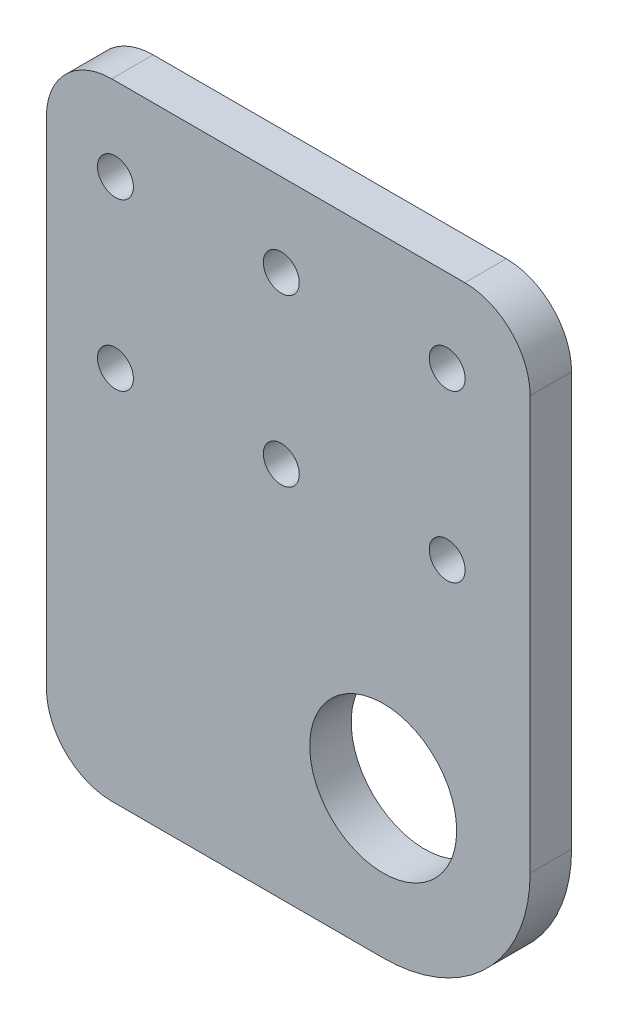
from build123d import *

# Parameters (mm, degrees)
SKETCH1_W            = 74.07
SKETCH1_H            = 50.8
BOSS_EXTRUDE1_DEPTH  = 6.35
FILLET1_R            = 10
M5_CLEARANCE_HOLE1_D = 5.5
BOSS_EXTRUDE2_DEPTH  = 6.35
SKETCH5_R            = 11.25
CUT_EXTRUDE1_DEPTH   = 7.35
FILLET2_R            = 10
FILLET3_R            = 22.5


with BuildPart() as part:
    # Sketch1 → Boss-Extrude1 (new body)
    with BuildSketch(Plane.XY):
        Rectangle(SKETCH1_W, SKETCH1_H)
    extrude(amount=BOSS_EXTRUDE1_DEPTH)

    # Fillet1
    fillet1_edges = [part.edges().sort_by_distance(p)[0] for p in [
        (-37.035, 25.4, 3.175),
        (37.035, 25.4, 3.175),
        (37.035, -25.4, 3.175),
        (-37.035, -25.4, 3.175),
    ]]
    fillet(fillet1_edges, radius=FILLET1_R)

    # M5 Clearance Hole1 (through all)
    with Locations(Plane.XY.offset(6.35)):
        with Locations((-26.465, 12.7), (-26.465, -12.7), (-1.065, -12.7), (-1.065, 12.7), (24.335, 12.7), (24.335, -12.7)):
            Hole(M5_CLEARANCE_HOLE1_D / 2)

    # Sketch4 → Boss-Extrude2 (add)
    with BuildSketch(Plane.XY.offset(6.35)):
        Polygon((37.035, -15.4), (37.035, -70.4), (-37.035, -70.4), (-37.035, -15.4), (-27.035, -25.4), (27.035, -25.4), align=None)
    extrude(amount=-BOSS_EXTRUDE2_DEPTH)

    # Sketch5 → Cut-Extrude1 (cut, through all)
    with BuildSketch(Plane.XY.offset(6.35)):
        with Locations((14.535, -47.9)):
            Circle(SKETCH5_R)
    extrude(amount=-CUT_EXTRUDE1_DEPTH, mode=Mode.SUBTRACT)

    # Fillet2
    fillet2_edges = [part.edges().sort_by_distance(p)[0] for p in [
        (-37.035, -70.4, 3.175),
    ]]
    fillet(fillet2_edges, radius=FILLET2_R)

    # Fillet3
    fillet3_edges = [part.edges().sort_by_distance(p)[0] for p in [
        (37.035, -70.4, 3.175),
    ]]
    fillet(fillet3_edges, radius=FILLET3_R)


solid = part.part
